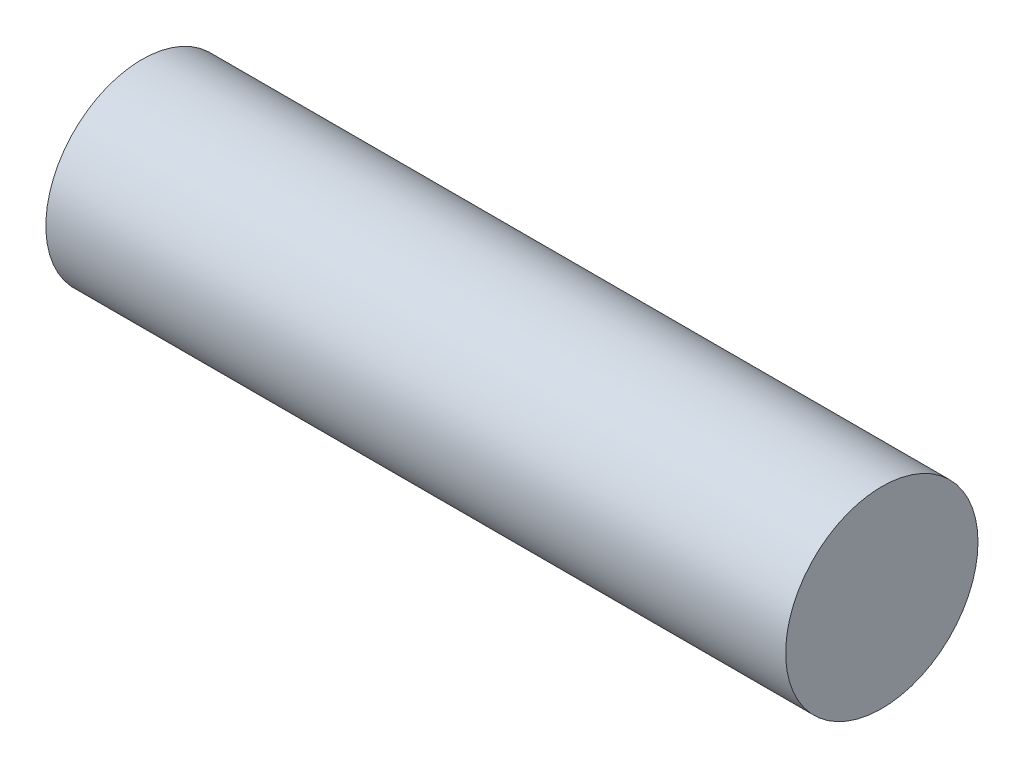
from build123d import *

# Parameters (mm, degrees)
SKETCH1_R           = 260
SKETCH1_R_2         = 250
EXTRUDE_THIN1_DEPTH = 2000
BOSS_EXTRUDE1_START = 1990
SKETCH1_2_R         = 250
BOSS_EXTRUDE1_DEPTH = 10
SKETCH1_3_R         = 250
BOSS_EXTRUDE2_DEPTH = 10


with BuildPart() as part:
    # Sketch1 → Extrude-Thin1 (new body)
    with BuildSketch(Plane(origin=(0, 0, 0), x_dir=(0, 0, -1), z_dir=(1, 0, 0))):
        Circle(SKETCH1_R)
        Circle(SKETCH1_R_2, mode=Mode.SUBTRACT)
    extrude(amount=EXTRUDE_THIN1_DEPTH)

    # Sketch1_2 → Boss-Extrude1 (add)
    with BuildSketch(Plane(origin=(0, 0, 0), x_dir=(0, 0, -1), z_dir=(1, 0, 0)).offset(BOSS_EXTRUDE1_START)):
        Circle(SKETCH1_2_R)
    extrude(amount=BOSS_EXTRUDE1_DEPTH)

    # Sketch1_3 → Boss-Extrude2 (add)
    with BuildSketch(Plane(origin=(0, 0, 0), x_dir=(0, 0, -1), z_dir=(1, 0, 0))):
        Circle(SKETCH1_3_R)
    extrude(amount=BOSS_EXTRUDE2_DEPTH)


solid = part.part
